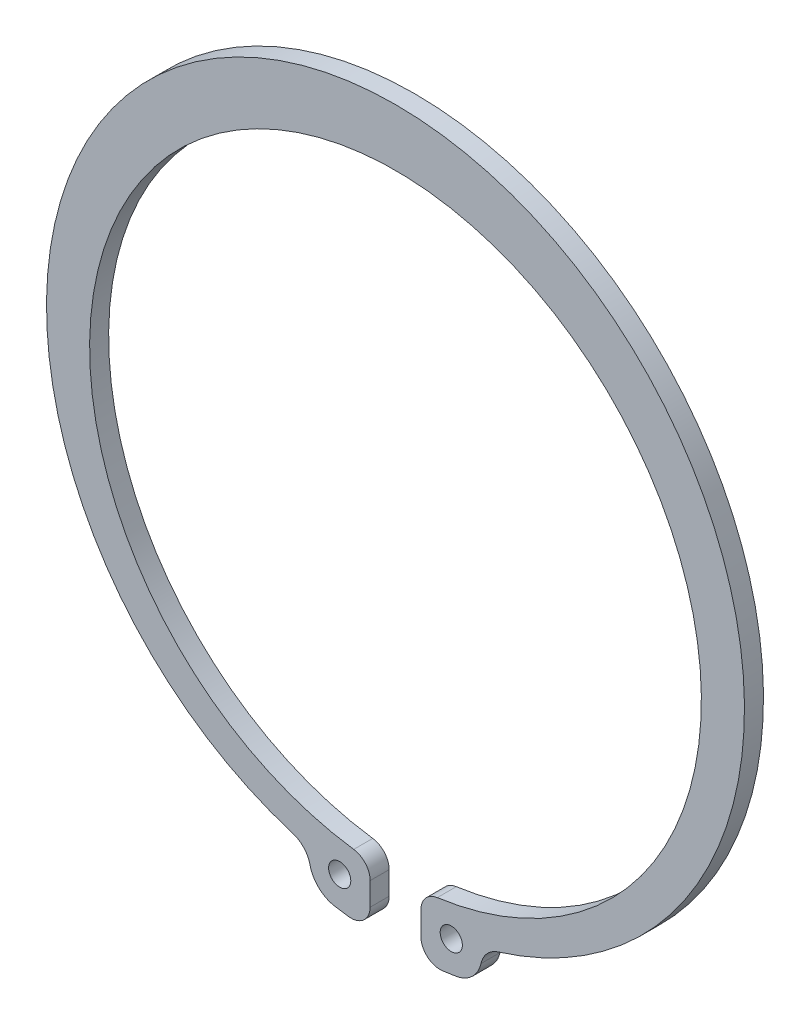
from build123d import *

# Parameters (mm, degrees)
SKETCH1_R      = 1.75
EXTRUDE1_DEPTH = 3


with BuildPart() as part:
    # Sketch1 → Extrude1 (new body)
    with BuildSketch(Plane.XY):
        with BuildLine():
            Line((-4, -50.76970061), (-4, -54.401493546))
            ThreePointArc((-4, -54.401493546), (-5.018660435, -56.654112805), (-7.382862352, -57.376962655))
            ThreePointArc((-7.382862352, -57.376962655), (-8.491134253, -57.223449207), (-9.596229972, -57.048530834))
            ThreePointArc((-9.596229972, -57.048530834), (-12.103146033, -55.797735176), (-13.484767706, -53.360474528))
            ThreePointArc((-13.484767706, -53.360474528), (-14.450357204, -51.517657712), (-16.210841333, -50.409040319))
            ThreePointArc((-16.210841333, -50.409040319), (0, 57.25), (16.210841333, -50.409040319))
            ThreePointArc((16.210841333, -50.409040319), (14.450357204, -51.517657712), (13.484767706, -53.360474528))
            ThreePointArc((13.484767706, -53.360474528), (12.103146033, -55.797735176), (9.596229972, -57.048530834))
            ThreePointArc((9.596229972, -57.048530834), (8.491134253, -57.223449207), (7.382862352, -57.376962655))
            ThreePointArc((7.382862352, -57.376962655), (5.018660435, -56.654112805), (4, -54.401493546))
            Line((4, -54.401493546), (4, -50.76970061))
            ThreePointArc((4, -50.76970061), (4.738444308, -48.79856747), (6.590243902, -47.797815696))
            ThreePointArc((6.590243902, -47.797815696), (0, 48.25), (-6.590243902, -47.797815696))
            ThreePointArc((-6.590243902, -47.797815696), (-4.738444308, -48.79856747), (-4, -50.76970061))
        make_face()
        with Locations((-8.8, -52.315031301)):
            Circle(SKETCH1_R, mode=Mode.SUBTRACT)
        with Locations((8.8, -52.315031301)):
            Circle(SKETCH1_R, mode=Mode.SUBTRACT)
    extrude(amount=EXTRUDE1_DEPTH)


solid = part.part
